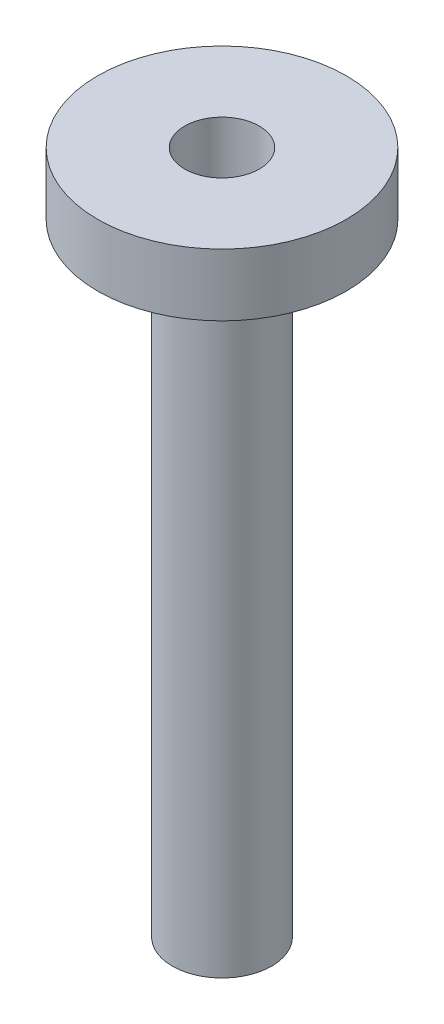
from build123d import *


with BuildPart() as part:
    # Sketch1 → Revolve1 (revolve)
    with BuildSketch(Plane.XY):
        Polygon((-3.81, 0), (-12.7, 0), (-12.7, -6.35), (-11.1125, -6.35), (-11.1125, -4.318), (-8.0645, -4.318), (-8.0645, -6.35), (-5.08, -6.35), (-5.08, -69.85), (-3.81, -68.58), align=None)
    revolve(axis=Axis((0, 0, 0), (0, -1, 0)))


solid = part.part
